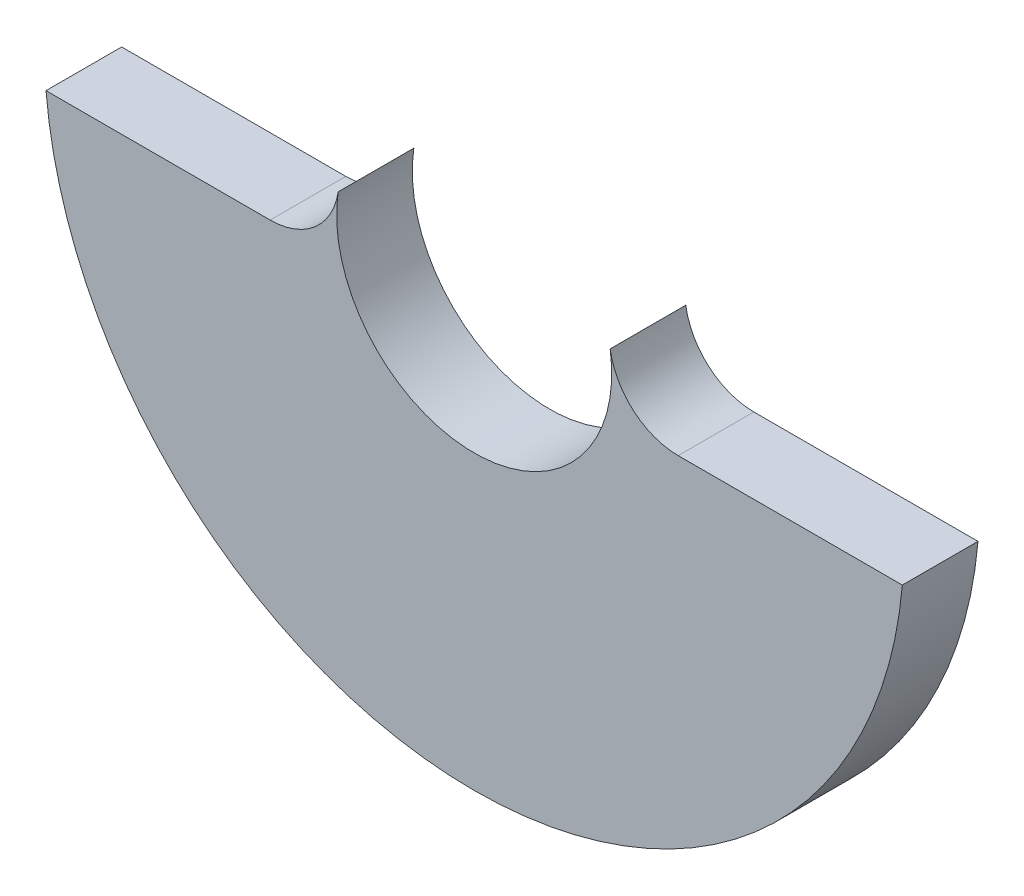
from build123d import *

# Parameters (mm, degrees)
SKETCH1_R           = 25
SKETCH1_R_2         = 8
BASE_EXTRUDE_DEPTH  = 4.4
CUT_EXTRUDE1_DEPTH  = 5.4
BOSS_EXTRUDE1_DEPTH = 4.4


with BuildPart() as part:
    # Sketch1 → Base-Extrude (new body)
    with BuildSketch(Plane.XY):
        Circle(SKETCH1_R)
        Circle(SKETCH1_R_2, mode=Mode.SUBTRACT)
    extrude(amount=BASE_EXTRUDE_DEPTH)

    # Sketch2 → Cut-Extrude1 (cut, through all)
    with BuildSketch(Plane.XY.offset(4.4)):
        Polygon((-31.283198073, -2.2), (32.499555714, -2.2), (32.499555714, 32.618237466), (-31.739332188, 32.618237466), align=None)
    extrude(amount=-CUT_EXTRUDE1_DEPTH, mode=Mode.SUBTRACT)

    # Sketch3 → Boss-Extrude1 (add)
    with BuildSketch(Plane.XY.offset(4.4)):
        with BuildLine():
            Line((7.691553809, -2.2), (11.86423196, -2.2))
            ThreePointArc((11.86423196, -2.2), (9.256550998, -1.233150178), (7.909487973, 1.2))
            ThreePointArc((7.909487973, 1.2), (7.983616109, -0.511736089), (7.691553809, -2.2))
        make_face()
        with BuildLine():
            Line((-11.86423196, -2.2), (-7.691553809, -2.2))
            ThreePointArc((-7.691553809, -2.2), (-7.983616109, -0.511736089), (-7.909487973, 1.2))
            ThreePointArc((-7.909487973, 1.2), (-9.256550998, -1.233150178), (-11.86423196, -2.2))
        make_face()
    extrude(amount=-BOSS_EXTRUDE1_DEPTH)


solid = part.part
